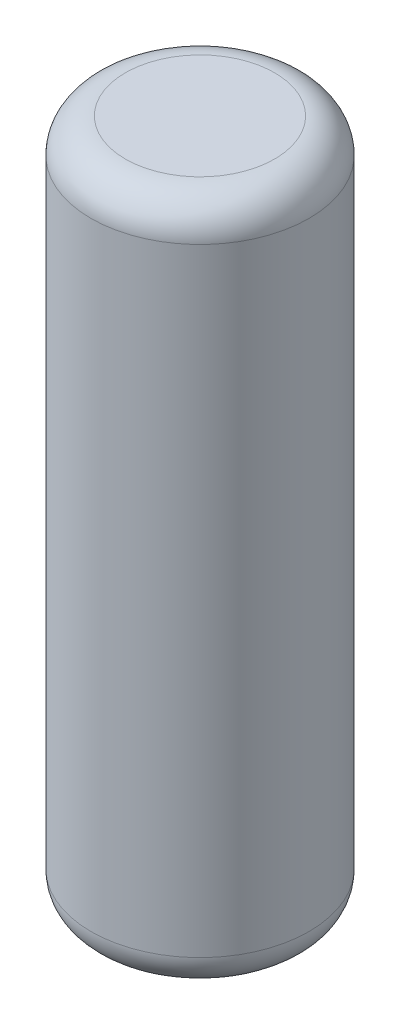
from build123d import *

# Parameters (mm, degrees)
SKETCH1_R           = 1.58877
BOSS_EXTRUDE1_DEPTH = 5
FILLET1_R           = 0.5


with BuildPart() as part:
    # Sketch1 → Boss-Extrude1 (new body, symmetric)
    with BuildSketch(Plane(origin=(0, 0, 0), x_dir=(1, 0, 0), z_dir=(0, 1, 0))):
        with Locations(Location((0, 0, 0), (0, 0, 270))):  # turned: the seam where the file's is
            Circle(SKETCH1_R)
    extrude(amount=BOSS_EXTRUDE1_DEPTH, both=True)

    # Fillet1
    fillet1_edges = [part.edges().sort_by_distance(p)[0] for p in [
        (0, -5, -1.58877),
        (0, 5, -1.58877),
    ]]
    fillet(fillet1_edges, radius=FILLET1_R)


solid = part.part
